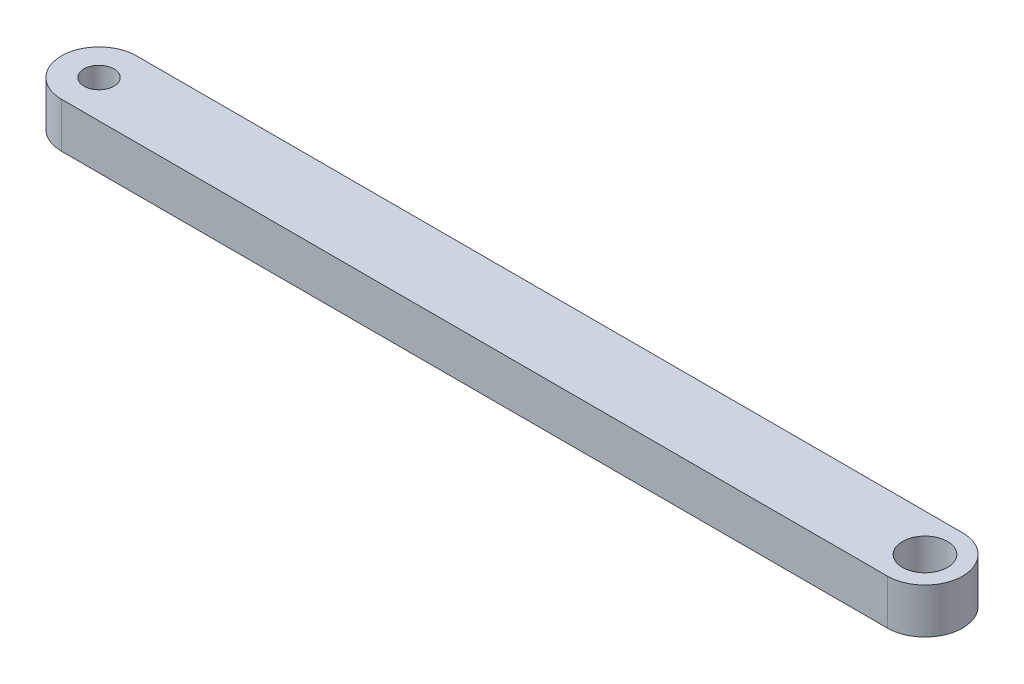
from build123d import *

# Parameters (mm, degrees)
SKETCH1_R           = 1.5
SKETCH1_R_2         = 1
BOSS_EXTRUDE1_DEPTH = 3


with BuildPart() as part:
    # Sketch1 → Boss-Extrude1 (new body)
    with BuildSketch(Plane.XZ):
        with BuildLine():
            Line((46, 2.5), (-9, 2.5))
            ThreePointArc((-9, 2.5), (-11.5, 0), (-9, -2.5))
            Line((-9, -2.5), (46, -2.5))
            ThreePointArc((46, -2.5), (48.5, 0), (46, 2.5))
        make_face()
        with Locations((46, 0)):
            Circle(SKETCH1_R, mode=Mode.SUBTRACT)
        with Locations((-9, 0)):
            Circle(SKETCH1_R_2, mode=Mode.SUBTRACT)
    extrude(amount=-BOSS_EXTRUDE1_DEPTH)


solid = part.part
